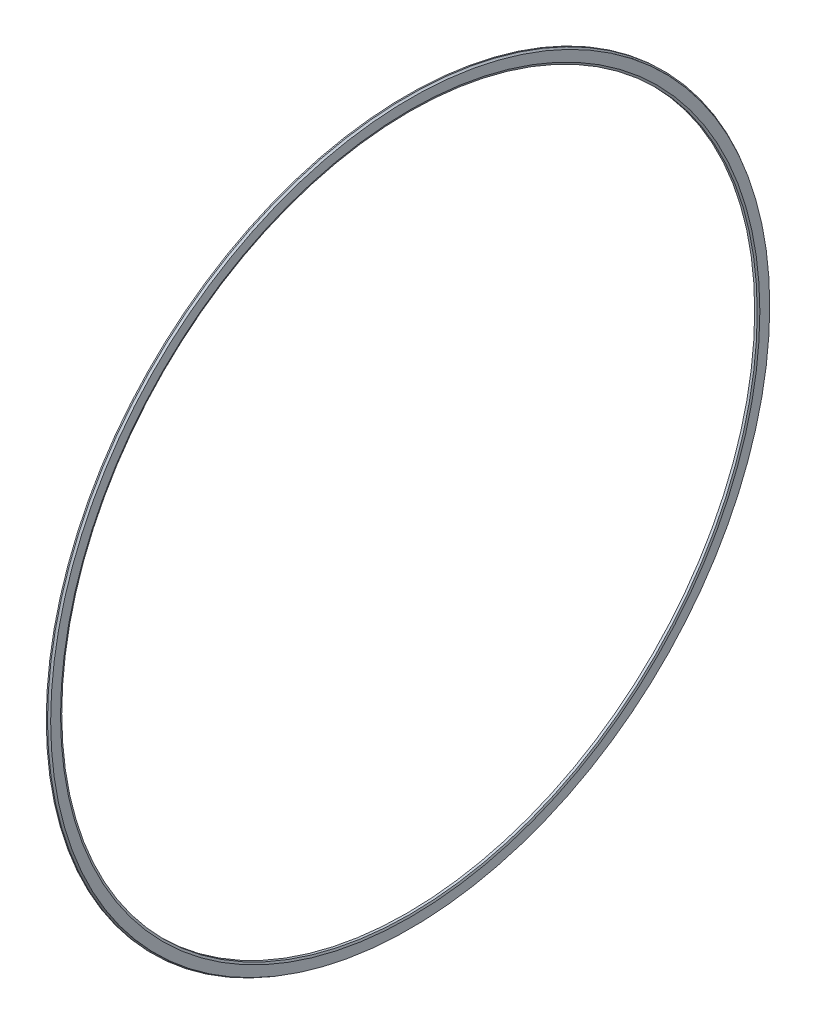
from build123d import *


with BuildPart() as part:
    # 草图1 → 旋转1 (revolve)
    with BuildSketch(Plane.XY):
        with BuildLine():
            Line((0, 44.55), (0.15, 44.55))
            ThreePointArc((0.15, 44.55), (0.260426662, 44.453354538), (0.4, 44.408037035))
            Line((0.4, 44.408037035), (0.4, 43.185990161))
            Line((0.4, 43.185990161), (0.312098656, 42.95))
            Line((0.312098656, 42.95), (0, 42.95))
            Line((0, 42.95), (0, 44.55))
        make_face()
    revolve(axis=Axis((0, 0, 0), (1, 0, 0)))


solid = part.part
